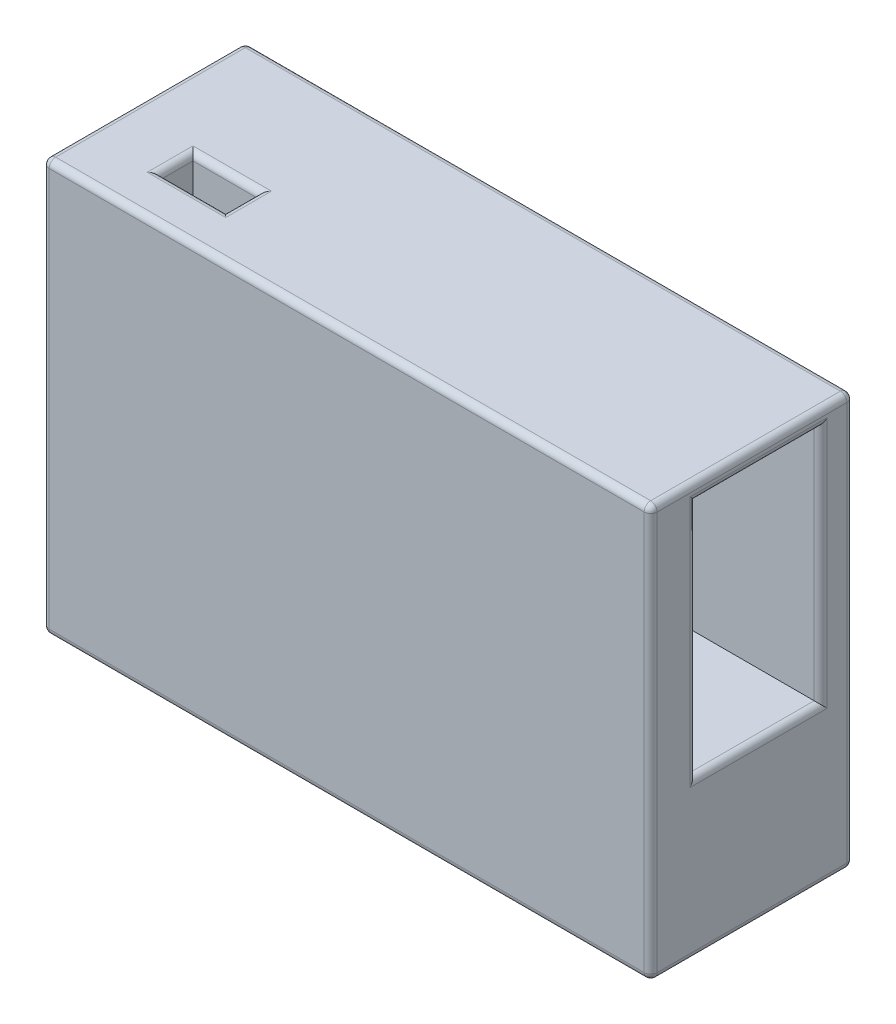
from build123d import *

# Parameters (mm, degrees)
SKETCH1_W           = 93
SKETCH1_H           = 63
BOSS_EXTRUDE1_DEPTH = 31
SKETCH2_W           = 19
SKETCH2_H           = 36.5
CUT_EXTRUDE1_DEPTH  = 31
SKETCH3_W           = 10
SKETCH3_H           = 5
CUT_EXTRUDE2_DEPTH  = 31
FILLET1_R           = 1


with BuildPart() as part:
    # Sketch1 → Boss-Extrude1 (new body)
    with BuildSketch(Plane.XY):
        Rectangle(SKETCH1_W, SKETCH1_H)
    extrude(amount=BOSS_EXTRUDE1_DEPTH)

    # Sketch2 → Cut-Extrude1 (cut)
    with BuildSketch(Plane(origin=(46.5, 0, 0), x_dir=(0, 0, -1), z_dir=(1, 0, 0))):
        with Locations((-14.5, 10.75)):
            Rectangle(SKETCH2_W, SKETCH2_H)
    extrude(amount=-CUT_EXTRUDE1_DEPTH, mode=Mode.SUBTRACT)

    # Sketch3 → Cut-Extrude2 (cut)
    with BuildSketch(Plane(origin=(0, 31.5, 0), x_dir=(1, 0, 0), z_dir=(0, 1, 0))):
        with Locations((-30.5, -21.5)):
            Rectangle(SKETCH3_W, SKETCH3_H)
    extrude(amount=-CUT_EXTRUDE2_DEPTH, mode=Mode.SUBTRACT)

    # Fillet1
    fillet1_edges = [part.edges().sort_by_distance(p)[0] for p in [
        (-46.5, 0, 31),
        (0, -31.5, 31),
        (46.5, 10.75, 24),
        (46.5, -7.5, 14.5),
        (46.5, 10.75, 5),
        (46.5, 29, 14.5),
        (-35.5, 31.5, 21.5),
        (-30.5, 31.5, 24),
        (-25.5, 31.5, 21.5),
        (-30.5, 31.5, 19),
        (46.5, 0, 31),
        (0, -31.5, 0),
        (-46.5, 0, 0),
        (0, 31.5, 0),
        (46.5, 0, 0),
        (46.5, -31.5, 15.5),
        (-46.5, -31.5, 15.5),
        (-46.5, 31.5, 15.5),
        (46.5, 31.5, 15.5),
        (0, 31.5, 31),
    ]]
    fillet(fillet1_edges, radius=FILLET1_R)


solid = part.part
